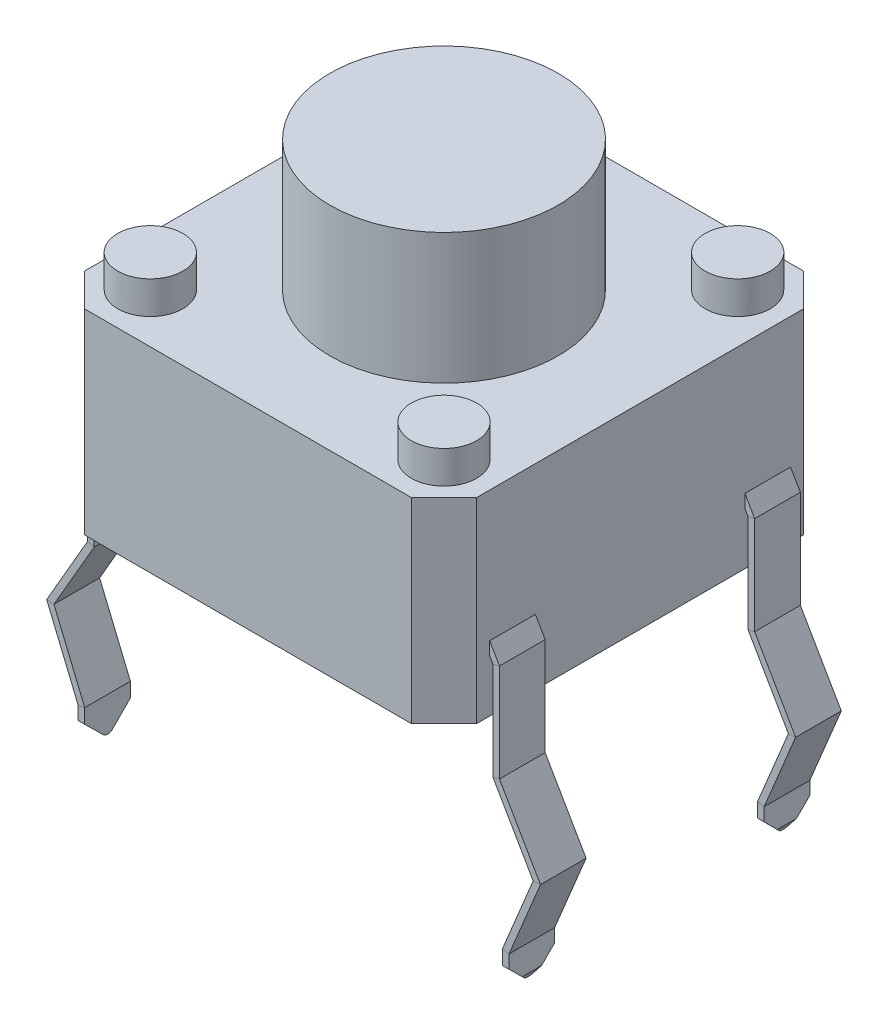
from build123d import *

# Parameters (mm, degrees)
SKETCH1_W               = 6.01
SKETCH1_H               = 6.01
BOSS_EXTRUDE1_DEPTH     = 3
CHAMFER1_SIZE           = 0.5
SKETCH3_R               = 1.75
BOSS_EXTRUDE2_DEPTH     = 2
SKETCH4_R               = 0.5
BOSS_EXTRUDE6_DEPTH     = 0.5
SKETCH5_R               = 0.5
BOSS_EXTRUDE7_DEPTH     = 0.5
SKETCH6_W               = 0.7
SKETCH6_H               = 0.2
MIRROR2_COPY_1_SKETCH_W = 0.7
MIRROR2_COPY_1_SKETCH_H = 0.2
CUT_EXTRUDE1_DEPTH      = 4.782799277


with BuildPart() as part:
    # Sketch1 → Boss-Extrude1 (new body)
    with BuildSketch(Plane(origin=(0, 0, 0), x_dir=(1, 0, 0), z_dir=(0, 1, 0))):
        Rectangle(SKETCH1_W, SKETCH1_H)
    extrude(amount=BOSS_EXTRUDE1_DEPTH)

    # Chamfer1
    chamfer1_edges = [part.edges().sort_by_distance(p)[0] for p in [
        (3.005, 1.5, 3.005),
        (-3.005, 1.5, 3.005),
        (-3.005, 1.5, -3.005),
        (3.005, 1.5, -3.005),
    ]]
    chamfer(chamfer1_edges, length=CHAMFER1_SIZE)

    # Sketch3 → Boss-Extrude2 (add)
    with BuildSketch(Plane(origin=(0, 3, 0), x_dir=(1, 0, 0), z_dir=(0, 1, 0))):
        Circle(SKETCH3_R)
    extrude(amount=BOSS_EXTRUDE2_DEPTH)

    # Sketch4 → Boss-Extrude6 (add)
    with BuildSketch(Plane(origin=(0, 3, 0), x_dir=(1, 0, 0), z_dir=(0, 1, 0))):
        with Locations((2.25, 2.25)):
            Circle(SKETCH4_R)
        with Locations((2.25, -2.25)):
            Circle(SKETCH4_R)
        with Locations((-2.25, 2.25)):
            Circle(SKETCH4_R)
    extrude(amount=BOSS_EXTRUDE6_DEPTH)

    # Sketch5 → Boss-Extrude7 (add)
    with BuildSketch(Plane(origin=(0, 3, 0), x_dir=(1, 0, 0), z_dir=(0, 1, 0))):
        with Locations((-2.25, -2.25)):
            Circle(SKETCH5_R)
    extrude(amount=BOSS_EXTRUDE7_DEPTH)

    # Sweep1: sweep along a path in Sketch7
    with BuildLine(Plane.XY) as sweep1_path:
        Line((-3.005, 0.9), (-3.105, 0.726794919))
        Line((-3.105, 0.726794919), (-3.105, -0.773205081))
        Line((-3.105, -0.773205081), (-3.72715614, -1.850811126))
        Line((-3.72715614, -1.850811126), (-3.25, -3))
        Line((-3.25, -3), (-3.25, -3.5))
    # Sketch6 → Sweep1 (sweep)
    with BuildSketch(Plane.ZY.offset(3.005)):
        with Locations((-1.955, 0.9)):
            Rectangle(SKETCH6_W, SKETCH6_H)
    sweep1 = sweep(path=sweep1_path.line, transition=Transition.RIGHT)

    # Mirror1: Sweep1 across plane
    add(sweep1.mirror(Plane.XY))

    # Mirror2: Sweep1 across plane
    add(sweep1.mirror(Plane(origin=(0, 0, 0), x_dir=(0, 0, 1), z_dir=(1, 0, 0))))

    # Mirror2 copy 1: sweep along a path in Mirror2 copy 1 path
    with BuildLine(Plane(origin=(0, 0, 0), x_dir=(-1, 0, 0), z_dir=(0, 0, -1))) as mirror2_copy_1_path:
        Line((-3.005, 0.9), (-3.105, 0.726794919))
        Line((-3.105, 0.726794919), (-3.105, -0.773205081))
        Line((-3.105, -0.773205081), (-3.72715614, -1.850811126))
        Line((-3.72715614, -1.850811126), (-3.25, -3))
        Line((-3.25, -3), (-3.25, -3.5))
    # Mirror2 copy 1 sketch → Mirror2 copy 1 (sweep)
    with BuildSketch(Plane(origin=(3.005, 0, 0), x_dir=(0, 0, -1), z_dir=(1, 0, 0))):
        with Locations((-1.955, 0.9)):
            Rectangle(MIRROR2_COPY_1_SKETCH_W, MIRROR2_COPY_1_SKETCH_H)
    sweep(path=mirror2_copy_1_path.line, transition=Transition.RIGHT)

    # Sketch8 → Cut-Extrude1 (cut, symmetric)
    with BuildSketch(Plane(origin=(0, 0, 0), x_dir=(0, 0, -1), z_dir=(1, 0, 0))):
        with BuildLine():
            Line((-2.305, -3.211682602), (-2.305, -3.58660254))
            Line((-2.305, -3.58660254), (-1.605, -3.58660254))
            Line((-1.605, -3.58660254), (-1.605, -3.211682602))
            Line((-1.605, -3.211682602), (-1.881694927, -3.48928466))
            ThreePointArc((-1.881694927, -3.48928466), (-1.952077784, -3.518688814), (-2.022718654, -3.489910032))
            Line((-2.022718654, -3.489910032), (-2.305, -3.211682602))
        make_face()
    cut_extrude1 = extrude(amount=CUT_EXTRUDE1_DEPTH, both=True, mode=Mode.SUBTRACT)

    # Mirror3: Cut-Extrude1 across plane
    add(cut_extrude1.mirror(Plane.XY), mode=Mode.SUBTRACT)


solid = part.part
